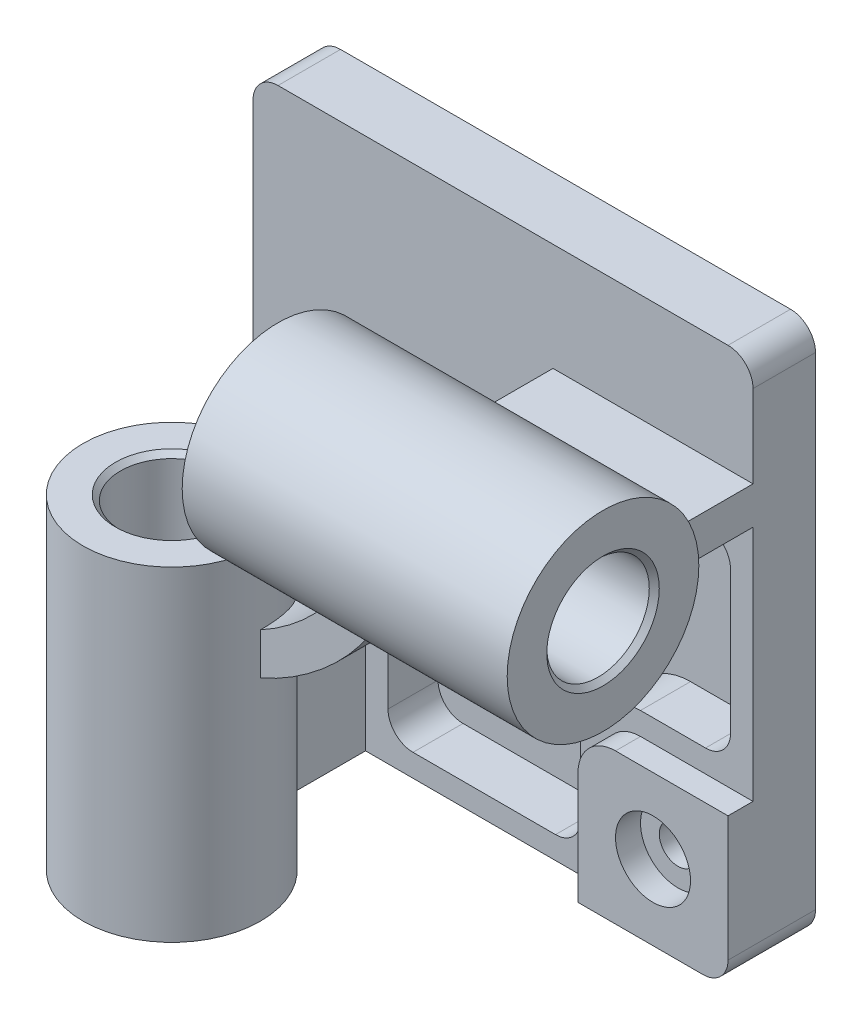
from build123d import *

# Parameters (mm, degrees)
BOSS_EXTRUDE1_DEPTH                     = 25
BOSS_EXTRUDE2_DEPTH                     = 10
CBORE_FOR_M8_HEX_HEAD_BOLT1_D           = 15
CBORE_FOR_M8_HEX_HEAD_BOLT1_CBORE_D     = 30
CBORE_FOR_M8_HEX_HEAD_BOLT1_CBORE_DEPTH = 10
BOSS_EXTRUDE3_DEPTH                     = 70
CUT_EXTRUDE1_DEPTH                      = 20
SKETCH7_R                               = 35.5
BOSS_EXTRUDE4_DEPTH                     = 130
SKETCH8_R                               = 20.5
CUT_EXTRUDE2_DEPTH                      = 224
SKETCH9_R                               = 38.333333333
BOSS_EXTRUDE5_DEPTH                     = 130
SKETCH10_R                              = 20.5
CUT_EXTRUDE3_DEPTH                      = 211
CHAMFER1_SIZE                           = 2


with BuildPart() as part:
    # Sketch1 → Boss-Extrude1 (new body)
    with BuildSketch(Plane.XY):
        with BuildLine():
            Line((10, 0), (190, 0))
            ThreePointArc((190, 0), (197.071067812, 2.928932188), (200, 10))
            Line((200, 10), (200, 203))
            ThreePointArc((200, 203), (197.071067812, 210.071067812), (190, 213))
            Line((190, 213), (10, 213))
            ThreePointArc((10, 213), (2.928932188, 210.071067812), (0, 203))
            Line((0, 203), (0, 10))
            ThreePointArc((0, 10), (2.928932188, 2.928932188), (10, 0))
        make_face()
    extrude(amount=BOSS_EXTRUDE1_DEPTH)

    # Sketch2 → Boss-Extrude2 (add)
    with BuildSketch(Plane.XY.offset(25)):
        with BuildLine():
            Line((200, 60), (200, 10))
            ThreePointArc((200, 10), (197.071067812, 2.928932188), (190, 0))
            Line((190, 0), (140, 0))
            Line((140, 0), (140, 45))
            ThreePointArc((140, 45), (144.393398282, 55.606601718), (155, 60))
            Line((155, 60), (200, 60))
        make_face()
    extrude(amount=BOSS_EXTRUDE2_DEPTH)

    # CBORE for M8 Hex Head Bolt1 (through all)
    with Locations(Plane.XY.offset(35)):
        with Locations((170, 30)):
            CounterBoreHole(CBORE_FOR_M8_HEX_HEAD_BOLT1_D / 2, CBORE_FOR_M8_HEX_HEAD_BOLT1_CBORE_D / 2, CBORE_FOR_M8_HEX_HEAD_BOLT1_CBORE_DEPTH)

    # Sketch5 → Boss-Extrude3 (add)
    with BuildSketch(Plane.XY.offset(25)):
        with BuildLine():
            Line((30, 0), (30, 80))
            ThreePointArc((30, 80), (93.639610307, 106.360389693), (120, 170))
            Line((120, 170), (200, 170))
            Line((200, 170), (200, 155))
            Line((200, 155), (133.923048454, 155))
            ThreePointArc((133.923048454, 155), (104.246212025, 95.753787975), (45, 66.076951546))
            Line((45, 66.076951546), (45, 0))
            Line((45, 0), (30, 0))
        make_face()
    extrude(amount=BOSS_EXTRUDE3_DEPTH)

    # Sketch6 → Cut-Extrude1 (cut)
    with BuildSketch(Plane.XY.offset(25)):
        with BuildLine():
            Line((54, 50.752358514), (54, 19))
            ThreePointArc((54, 19), (56.928932188, 11.928932188), (64, 9))
            Line((64, 9), (121, 9))
            ThreePointArc((121, 9), (128.071067812, 11.928932188), (131, 19))
            Line((131, 19), (131, 45))
            ThreePointArc((131, 45), (138.029437252, 61.970562748), (155, 69))
            Line((155, 69), (181, 69))
            ThreePointArc((181, 69), (188.071067812, 71.928932188), (191, 79))
            Line((191, 79), (191, 136))
            ThreePointArc((191, 136), (188.071067812, 143.071067812), (181, 146))
            Line((181, 146), (149.247641486, 146))
            ThreePointArc((149.247641486, 146), (143.223496519, 143.981834214), (139.630896205, 138.741935484))
            ThreePointArc((139.630896205, 138.741935484), (110.610173055, 89.389826945), (61.258064516, 60.369103795))
            ThreePointArc((61.258064516, 60.369103795), (56.018165786, 56.776503481), (54, 50.752358514))
        make_face()
    extrude(amount=-CUT_EXTRUDE1_DEPTH, mode=Mode.SUBTRACT)

    # Sketch7 → Boss-Extrude4 (add)
    with BuildSketch(Plane(origin=(0, -10, 0), x_dir=(-1, 0, 0), z_dir=(0, -1, 0))):
        with Locations((-37.5, -95)):
            Circle(SKETCH7_R)
    extrude(amount=-BOSS_EXTRUDE4_DEPTH)

    # Sketch8 → Cut-Extrude2 (cut, through all)
    with BuildSketch(Plane.XZ.offset(10)):
        with Locations((37.5, 95)):
            Circle(SKETCH8_R)
    extrude(amount=-CUT_EXTRUDE2_DEPTH, mode=Mode.SUBTRACT)

    # Sketch9 → Boss-Extrude5 (add)
    with BuildSketch(Plane(origin=(210, 0, 0), x_dir=(0, 0, -1), z_dir=(1, 0, 0))):
        with Locations((-95, 162.5)):
            Circle(SKETCH9_R)
    extrude(amount=-BOSS_EXTRUDE5_DEPTH)

    # Sketch10 → Cut-Extrude3 (cut, through all)
    with BuildSketch(Plane(origin=(210, 0, 0), x_dir=(0, 0, -1), z_dir=(1, 0, 0))):
        with Locations((-95, 162.5)):
            Circle(SKETCH10_R)
    extrude(amount=-CUT_EXTRUDE3_DEPTH, mode=Mode.SUBTRACT)

    # Chamfer1
    chamfer1_edges = [part.edges().sort_by_distance(p)[0] for p in [
        (17, 120, 95),
        (17, -10, 95),
        (80, 162.5, 115.5),
        (210, 162.5, 115.5),
    ]]
    chamfer(chamfer1_edges, length=CHAMFER1_SIZE)


solid = part.part
